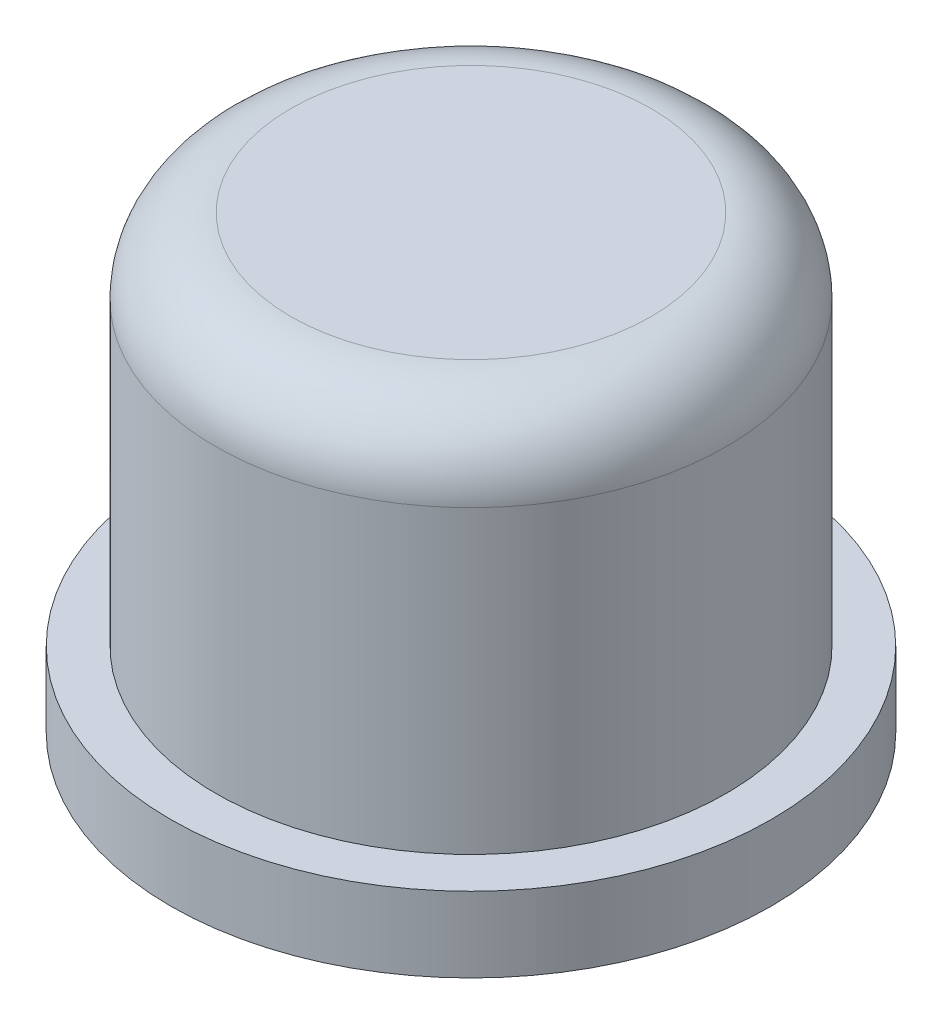
from build123d import *

# Parameters (mm, degrees)
FILLET1_R = 1


with BuildPart() as part:
    # Sketch1 → Revolve1 (revolve)
    with BuildSketch(Plane.XY):
        Polygon((0, 6), (-3.4, 6), (-3.4, 1), (-4, 1), (-4, 0), (-2.25, 0), (-2.25, 3), (0, 3), align=None)
    revolve(axis=Axis((0, 3, 0), (0, 1, 0)))

    # Fillet1
    fillet1_edges = [part.edges().sort_by_distance(p)[0] for p in [
        (3.4, 6, 0),
    ]]
    fillet(fillet1_edges, radius=FILLET1_R)


solid = part.part
